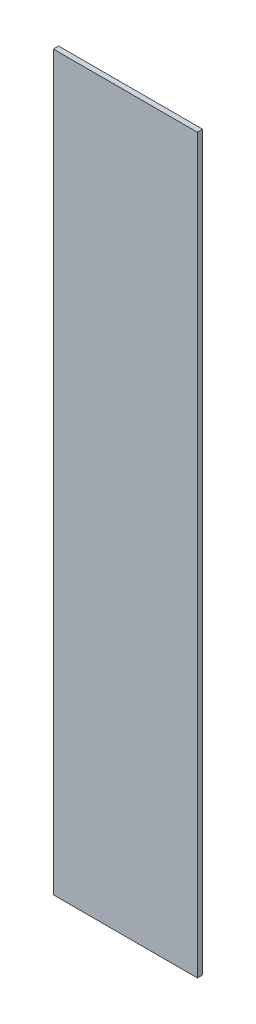
from build123d import *

# Parameters (mm, degrees)
SKETCH1_W           = 304.8
SKETCH1_H           = 1549.4
BOSS_EXTRUDE1_DEPTH = 11.1125


with BuildPart() as part:
    # Sketch1 → Boss-Extrude1 (new body)
    with BuildSketch(Plane.XY):
        with Locations((152.4, 774.7)):
            Rectangle(SKETCH1_W, SKETCH1_H)
    extrude(amount=BOSS_EXTRUDE1_DEPTH)


solid = part.part
